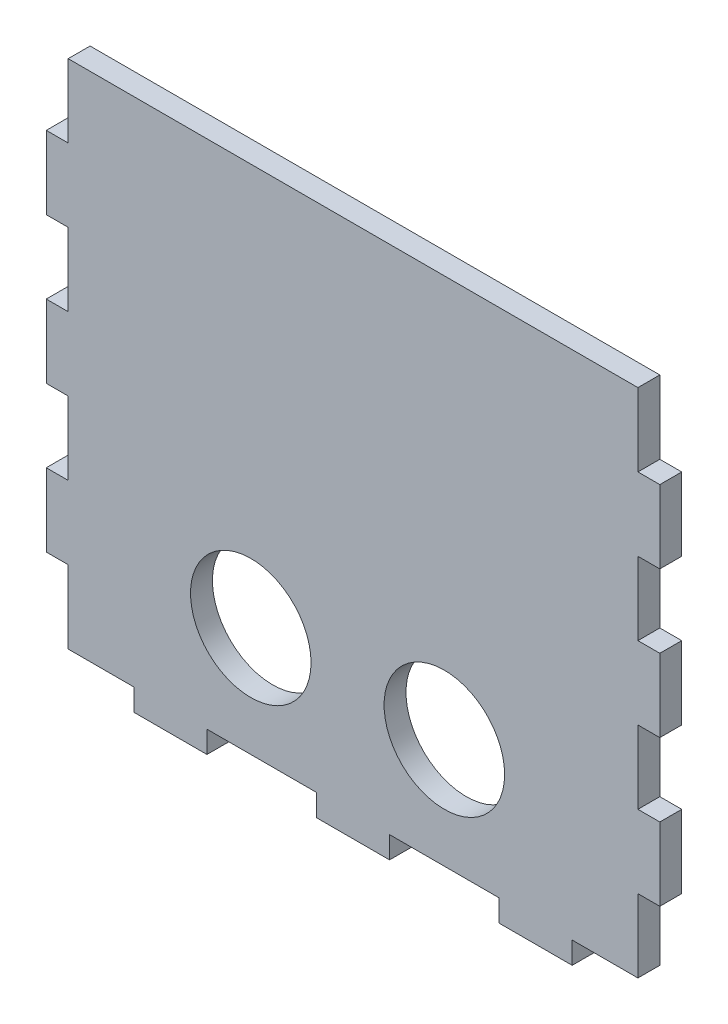
from build123d import *

# Parameters (mm, degrees)
ESQUISSE1_R        = 8.25
BOSS_EXTRU_1_DEPTH = 3


with BuildPart() as part:
    # Esquisse1 → Boss.-Extru.1 (new body)
    with BuildSketch(Plane.XY):
        Polygon((-69.538481563, 40.597826087), (8.461518437, 40.597826087), (8.461518437, 30.597826087), (11.461518437, 30.597826087), (11.461518437, 20.597826087), (8.461518437, 20.597826087), (8.461518437, 10.597826087), (11.461518437, 10.597826087), (11.461518437, 0.597826087), (8.461518437, 0.597826087), (8.461518437, -9.402173913), (11.461518437, -9.402173913), (11.461518437, -19.402173913), (8.461518437, -19.402173913), (8.461518437, -29.402173913), (-0.538481563, -29.402173913), (-0.538481563, -32.402173913), (-10.538481563, -32.402173913), (-10.538481563, -29.402173913), (-25.538481563, -29.402173913), (-25.538481563, -32.402173913), (-35.538481563, -32.402173913), (-35.538481563, -29.402173913), (-50.538481563, -29.402173913), (-50.538481563, -32.402173913), (-60.538481563, -32.402173913), (-60.538481563, -29.402173913), (-69.538481563, -29.402173913), (-69.538481563, -19.402173913), (-72.538481563, -19.402173913), (-72.538481563, -9.402173913), (-69.538481563, -9.402173913), (-69.538481563, 0.597826087), (-72.538481563, 0.597826087), (-72.538481563, 10.597826087), (-69.538481563, 10.597826087), (-69.538481563, 20.597826087), (-72.538481563, 20.597826087), (-72.538481563, 30.597826087), (-69.538481563, 30.597826087), align=None)
        with Locations((-18.038481563, -14.402173913)):
            Circle(ESQUISSE1_R, mode=Mode.SUBTRACT)
        with Locations((-44.538481563, -14.402173913)):
            Circle(ESQUISSE1_R, mode=Mode.SUBTRACT)
    extrude(amount=BOSS_EXTRU_1_DEPTH)


solid = part.part
